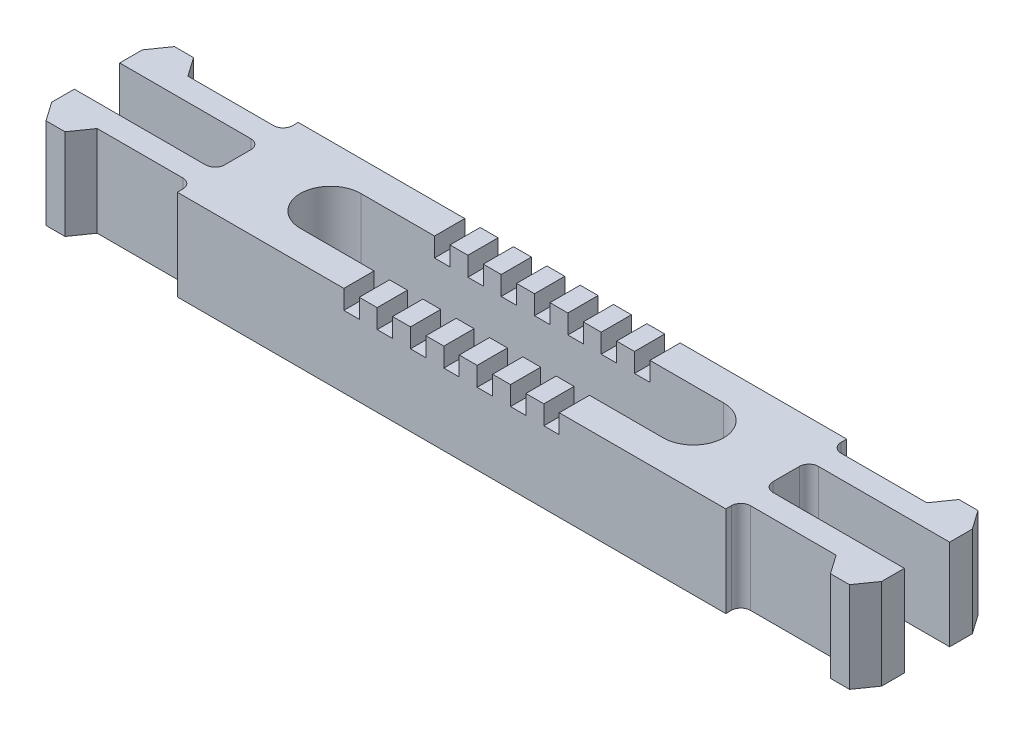
from build123d import *

# Parameters (mm, degrees)
SKETCH1_W            = 57.6
SKETCH1_H            = 12.7
BOSS_EXTRUDE1_DEPTH  = 9.525
BOSS_EXTRUDE2_DEPTH  = 9.525
MIRROR2_COPY_1_DEPTH = 9.525
FILLET1_R            = 1
CUT_EXTRUDE1_DEPTH   = 10.525
SKETCH3_W            = 1.62
SKETCH3_H            = 12.7
CUT_EXTRUDE2_DEPTH   = 2
LPATTERN1_COUNT      = 4
LPATTERN1_PITCH      = 3.5
LPATTERN1_COL_COUNT  = 4
LPATTERN1_COL_PITCH  = 3.5


with BuildPart() as part:
    # Sketch1 → Boss-Extrude1 (new body)
    with BuildSketch(Plane(origin=(0, 0, 0), x_dir=(1, 0, 0), z_dir=(0, 1, 0))):
        Rectangle(SKETCH1_W, SKETCH1_H)
    extrude(amount=BOSS_EXTRUDE1_DEPTH)

    # Sketch2 → Boss-Extrude2 (add)
    with BuildSketch(Plane(origin=(0, 9.525, 0), x_dir=(1, 0, 0), z_dir=(0, 1, 0))):
        Polygon((-28.8, 4.7625), (-38.8, 4.7625), (-40.189474334, 6.746875), (-42.189474334, 6.746875), (-43.578948667, 4.7625), (-43.578948667, 2.38125), (-28.8, 2.38125), align=None)
    boss_extrude2 = extrude(amount=-BOSS_EXTRUDE2_DEPTH)

    # Mirror1: Boss-Extrude2 across plane
    add(boss_extrude2.mirror(Plane(origin=(0, 0, 0), x_dir=(0, 0, 1), z_dir=(1, 0, 0))))

    # Mirror2: Boss-Extrude2 across plane
    add(boss_extrude2.mirror(Plane.XY))

    # Mirror2 copy 1 sketch → Mirror2 copy 1 (add)
    with BuildSketch(Plane(origin=(0, 9.525, 0), x_dir=(-1, 0, 0), z_dir=(0, 1, 0))):
        Polygon((-28.8, 4.7625), (-38.8, 4.7625), (-40.189474334, 6.746875), (-42.189474334, 6.746875), (-43.578948667, 4.7625), (-43.578948667, 2.38125), (-28.8, 2.38125), align=None)
    extrude(amount=-MIRROR2_COPY_1_DEPTH)

    # Fillet1
    fillet1_edges = [part.edges().sort_by_distance(p)[0] for p in [
        (-28.8, 4.7625, -4.7625),
        (-28.8, 4.7625, -2.38125),
        (28.8, 4.7625, -4.7625),
        (28.8, 4.7625, -2.38125),
        (-28.8, 4.7625, 4.7625),
        (-28.8, 4.7625, 2.38125),
        (28.8, 4.7625, 4.7625),
        (28.8, 4.7625, 2.38125),
    ]]
    fillet(fillet1_edges, radius=FILLET1_R)

    # Sketch4 → Cut-Extrude1 (cut, through all)
    with BuildSketch(Plane(origin=(0, 9.525, 0), x_dir=(1, 0, 0), z_dir=(0, 1, 0))):
        with BuildLine():
            Line((-19.05, 3.175), (19.05, 3.175))
            ThreePointArc((19.05, 3.175), (22.225, 0), (19.05, -3.175))
            Line((19.05, -3.175), (-19.05, -3.175))
            ThreePointArc((-19.05, -3.175), (-22.225, 0), (-19.05, 3.175))
        make_face()
    extrude(amount=-CUT_EXTRUDE1_DEPTH, mode=Mode.SUBTRACT)

    # Sketch3 → Cut-Extrude2 (cut)
    with BuildSketch(Plane(origin=(0, 9.525, 0), x_dir=(1, 0, 0), z_dir=(0, 1, 0))):
        Rectangle(SKETCH3_W, SKETCH3_H)
    cut_extrude2 = extrude(amount=-CUT_EXTRUDE2_DEPTH, mode=Mode.SUBTRACT)

    # LPattern1: Cut-Extrude2 ×4
    with Locations(*[(-i * LPATTERN1_PITCH, 0, 0) for i in range(1, LPATTERN1_COUNT)]):
        add(cut_extrude2, mode=Mode.SUBTRACT)

    # LPattern1 col: Cut-Extrude2 ×4
    with Locations(*[(i * LPATTERN1_COL_PITCH, 0, 0) for i in range(1, LPATTERN1_COL_COUNT)]):
        add(cut_extrude2, mode=Mode.SUBTRACT)


solid = part.part
